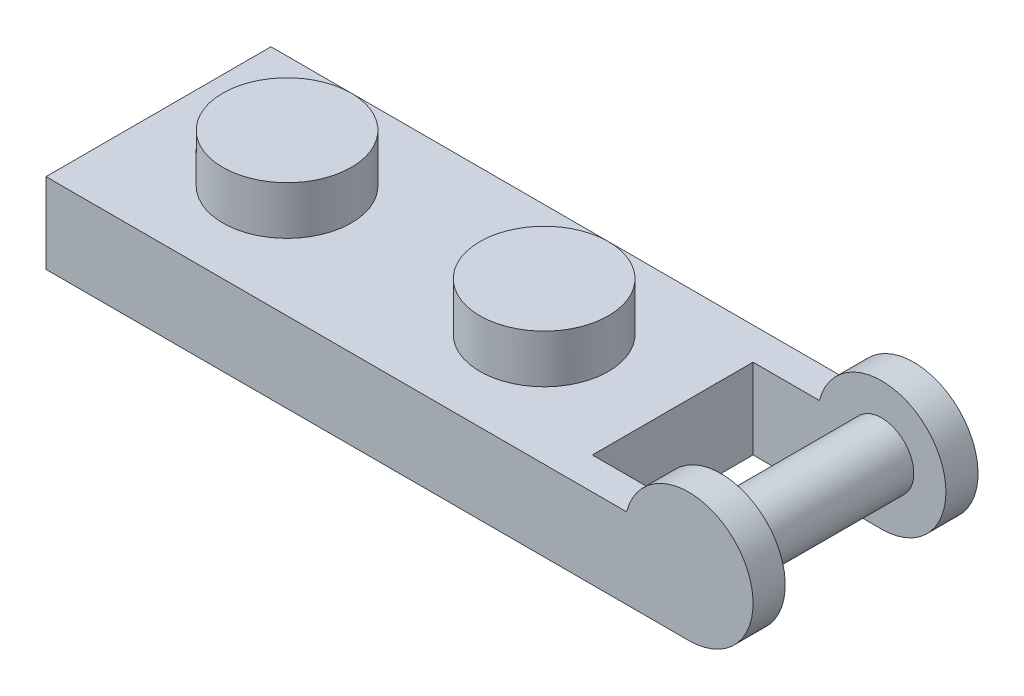
from build123d import *

# Parameters (mm, degrees)
SKETCH1_W                       = 20.32
SKETCH1_H                       = 3.175
BOSS_EXTRUDE2_DEPTH             = 4.445
SKETCH3_R                       = 2.54
BOSS_EXTRUDE3_DEPTH             = 1.905
SKETCH4_W                       = 17.78
SKETCH4_H                       = 5.08
CUT_EXTRUDE1_DEPTH              = 1.905
SKETCH5_R                       = 1.905
CUT_EXTRUDE2_DEPTH              = 2.54
SKETCH6_R                       = 1.905
SKETCH6_R_2                     = 0.9525
BOSS_EXTRUDE4_DEPTH             = 1.905
BOSS_EXTRUDE5_DEPTH             = 1.27
BOSS_EXTRUDE6_REACH             = 6.445
SKETCH9_R                       = 1.27
BOSS_EXTRUDE6_DIRECTION_2_REACH = 6.445


with BuildPart() as part:
    # Sketch1 → Boss-Extrude2 (new body, symmetric)
    with BuildSketch(Plane.XY):
        with Locations((0, -1.5875)):
            Rectangle(SKETCH1_W, SKETCH1_H)
    extrude(amount=BOSS_EXTRUDE2_DEPTH, both=True)

    # Sketch3 → Boss-Extrude3 (add)
    with BuildSketch(Plane(origin=(0, 0, 0), x_dir=(1, 0, 0), z_dir=(0, 1, 0))):
        with Locations((-5.08, 0)):
            Circle(SKETCH3_R)
        with Locations((5.08, 0)):
            Circle(SKETCH3_R)
    extrude(amount=BOSS_EXTRUDE3_DEPTH)

    # Sketch4 → Cut-Extrude1 (cut)
    with BuildSketch(Plane.XZ.offset(3.175)):
        Rectangle(SKETCH4_W, SKETCH4_H)
    extrude(amount=-CUT_EXTRUDE1_DEPTH, mode=Mode.SUBTRACT)

    # Sketch5 → Cut-Extrude2 (cut)
    with BuildSketch(Plane.XZ.offset(1.27)):
        with Locations((-5.08, 0)):
            Circle(SKETCH5_R)
        with Locations((5.08, 0)):
            Circle(SKETCH5_R)
    extrude(amount=-CUT_EXTRUDE2_DEPTH, mode=Mode.SUBTRACT)

    # Sketch6 → Boss-Extrude4 (add)
    with BuildSketch(Plane.XZ.offset(1.27)):
        Circle(SKETCH6_R)
        Circle(SKETCH6_R_2, mode=Mode.SUBTRACT)
    extrude(amount=BOSS_EXTRUDE4_DEPTH)

    # Sketch8 → Boss-Extrude5 (add)
    with BuildSketch(Plane.XY.offset(4.445)):
        with BuildLine():
            Line((10.16, -3.175), (15.24, -3.175))
            ThreePointArc((15.24, -3.175), (17.248046314, 0.920425987), (12.780655575, 0))
            Line((12.780655575, 0), (10.16, 0))
            Line((10.16, 0), (10.16, -3.175))
        make_face()
    boss_extrude5 = extrude(amount=-BOSS_EXTRUDE5_DEPTH)

    # Mirror1: Boss-Extrude5 across plane
    add(boss_extrude5.mirror(Plane.XY))

    # Sketch9 → Boss-Extrude6 (add, up to next)
    with BuildSketch(Plane.XY, mode=Mode.PRIVATE) as boss_extrude6_sk1:
        with Locations((15.24, -0.635)):
            Circle(SKETCH9_R)
    boss_extrude6_tool1 = extrude(boss_extrude6_sk1.sketch, amount=BOSS_EXTRUDE6_REACH, mode=Mode.PRIVATE) - part.part
    add(boss_extrude6_tool1.solids().sort_by_distance((15.24, -0.635, 0))[0])

    # Sketch9 → Boss-Extrude6 direction 2 (add, up to next)
    with BuildSketch(Plane.XY, mode=Mode.PRIVATE) as boss_extrude6_direction_2_sk1:
        with Locations((15.24, -0.635)):
            Circle(SKETCH9_R)
    boss_extrude6_direction_2_tool1 = extrude(boss_extrude6_direction_2_sk1.sketch, amount=-BOSS_EXTRUDE6_DIRECTION_2_REACH, mode=Mode.PRIVATE) - part.part
    add(boss_extrude6_direction_2_tool1.solids().sort_by_distance((15.24, -0.635, 0))[0])


solid = part.part
